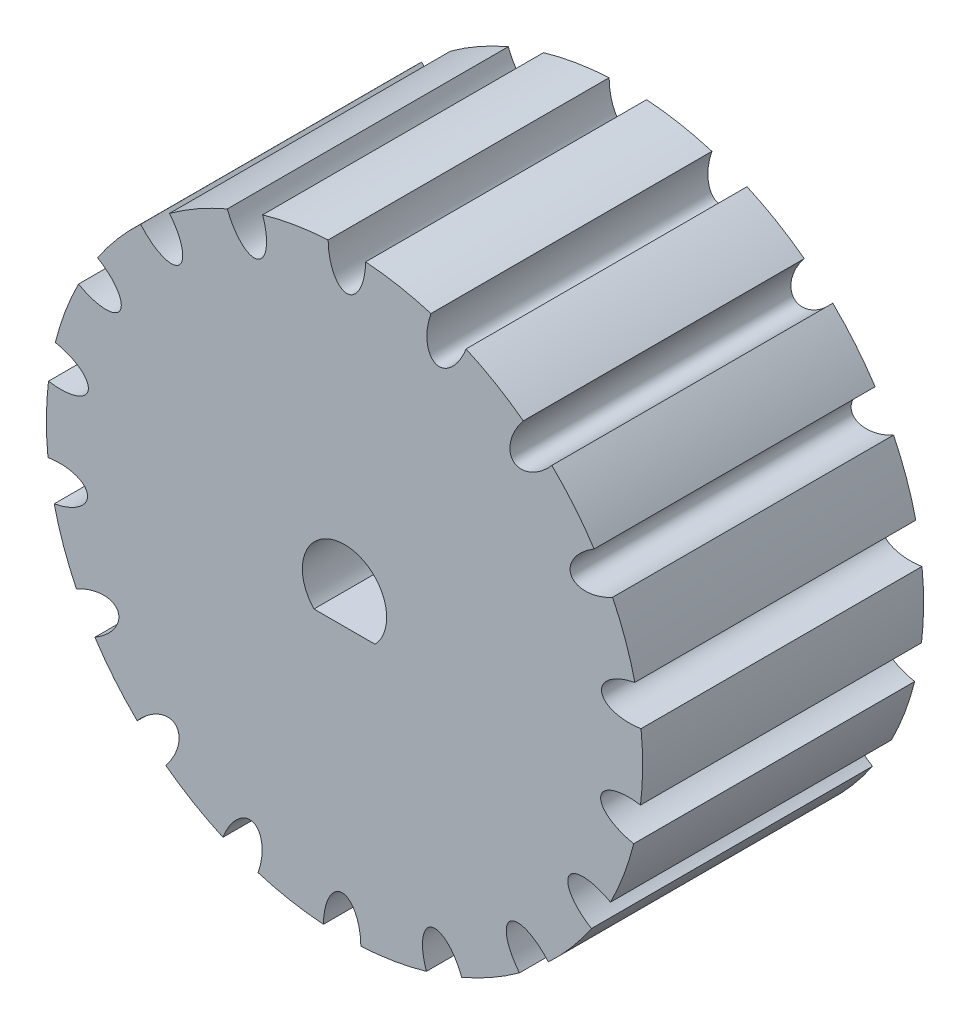
from build123d import *

# Parameters (mm, degrees)
SKETCH_1_R               = 15.91549431
EXTRUDE_1_DEPTH          = 15
CUT_EXTRUDE_1_DEPTH      = 15
SKETCH_3_RX              = 2
SKETCH_3_RY              = 1
CUT_EXTRUDE_2_DEPTH      = 15
PATTERN_CIRCULAR_1_COUNT = 18


with BuildPart() as part:
    # Эскиз1 → Бобышка-Вытянуть1 (new body)
    with BuildSketch(Plane.XY):
        Circle(SKETCH_1_R)
    extrude(amount=EXTRUDE_1_DEPTH)

    # Эскиз2 → Вырез-Вытянуть1 (cut)
    with BuildSketch(Plane.XY.offset(15)):
        with BuildLine():
            Line((1.630950643, -1.55), (-1.630950643, -1.55))
            ThreePointArc((-1.630950643, -1.55), (0, 2.25), (1.630950643, -1.55))
        make_face()
    extrude(amount=-CUT_EXTRUDE_1_DEPTH, mode=Mode.SUBTRACT)

    # Эскиз3 → Вырез-Вытянуть2 (cut)
    with BuildSketch(Plane.XY.offset(15)):
        with Locations(Location((0.125778317, 15.914997296), (0, 0, 90))):
            Ellipse(SKETCH_3_RX, SKETCH_3_RY)
    cut_extrude_2 = extrude(amount=-CUT_EXTRUDE_2_DEPTH, mode=Mode.SUBTRACT)

    # Круговой массив1: Вырез-Вытянуть2 ×18 about axis
    pattern_circular_1_axis = Axis((0, 0, 15), (0, 0, 1))
    for i in range(1, PATTERN_CIRCULAR_1_COUNT):
        add(cut_extrude_2.rotate(pattern_circular_1_axis, i * 360 / PATTERN_CIRCULAR_1_COUNT), mode=Mode.SUBTRACT)


solid = part.part
